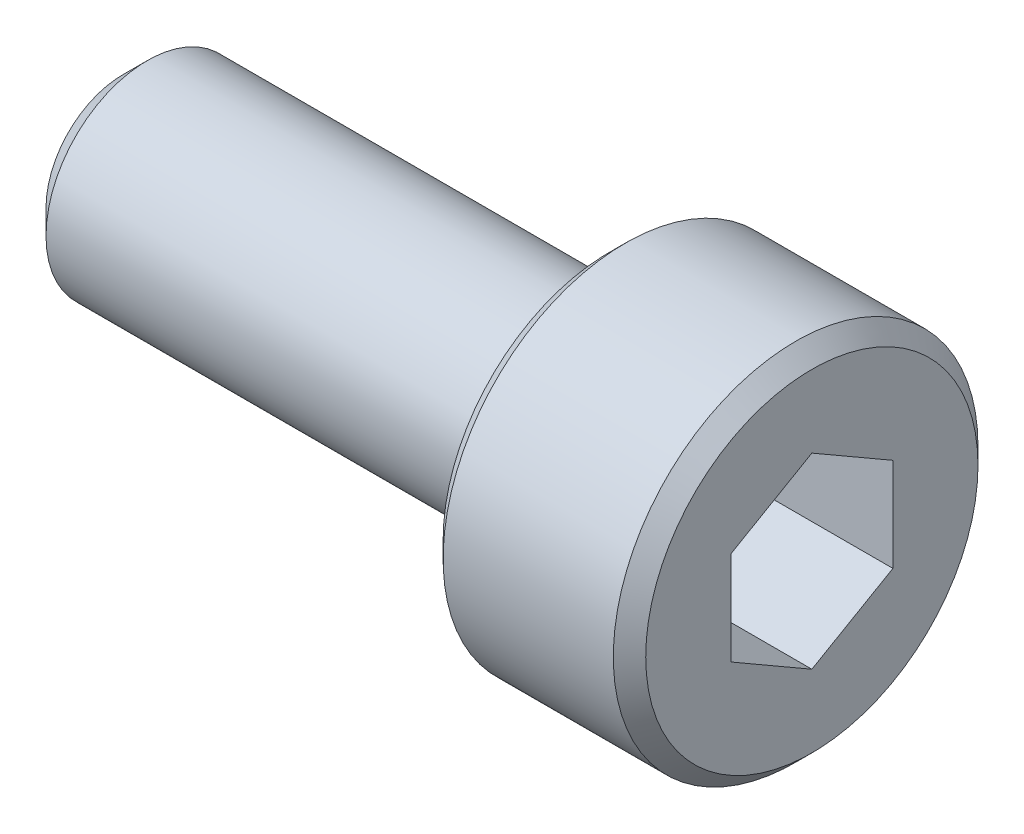
from build123d import *

# Parameters (mm, degrees)
SKETCH1_W          = 6
SKETCH1_H          = 1.25
CUT_EXTRUDE1_DEPTH = 2
CHAMFER1_SIZE      = 0.2
CHAMFER2_SIZE      = 0.3


with BuildPart() as part:
    # Sketch1 → Revolve1 (revolve)
    with BuildSketch(Plane(origin=(0, 0, 0), x_dir=(1, 0, 0), z_dir=(0, 1, 0))):
        with Locations((-3, -0.625)):
            Rectangle(SKETCH1_W, SKETCH1_H)
        Polygon((0, 1), (0, 0), (0, -1.25), (2.5, -1.25), (2.5, 1), align=None)
    revolve(axis=Axis((0, 0, 1.25), (-1, 0, 0)))

    # Sketch3 → Cut-Extrude1 (cut)
    with BuildSketch(Plane(origin=(2.5, 0, 0), x_dir=(0, 0, -1), z_dir=(1, 0, 0))):
        Polygon((-1.25, 1.154700538), (-2.25, 0.577350269), (-2.25, -0.577350269), (-1.25, -1.154700538), (-0.25, -0.577350269), (-0.25, 0.577350269), align=None)
    extrude(amount=-CUT_EXTRUDE1_DEPTH, mode=Mode.SUBTRACT)

    # Chamfer1
    chamfer1_edges = [part.edges().sort_by_distance(p)[0] for p in [
        (0, 0, 3.5),
        (2.5, 0, 3.5),
    ]]
    chamfer(chamfer1_edges, length=CHAMFER1_SIZE)

    # Chamfer2
    chamfer2_edges = [part.edges().sort_by_distance(p)[0] for p in [
        (-6, 0, 2.5),
    ]]
    chamfer(chamfer2_edges, length=CHAMFER2_SIZE)


solid = part.part
